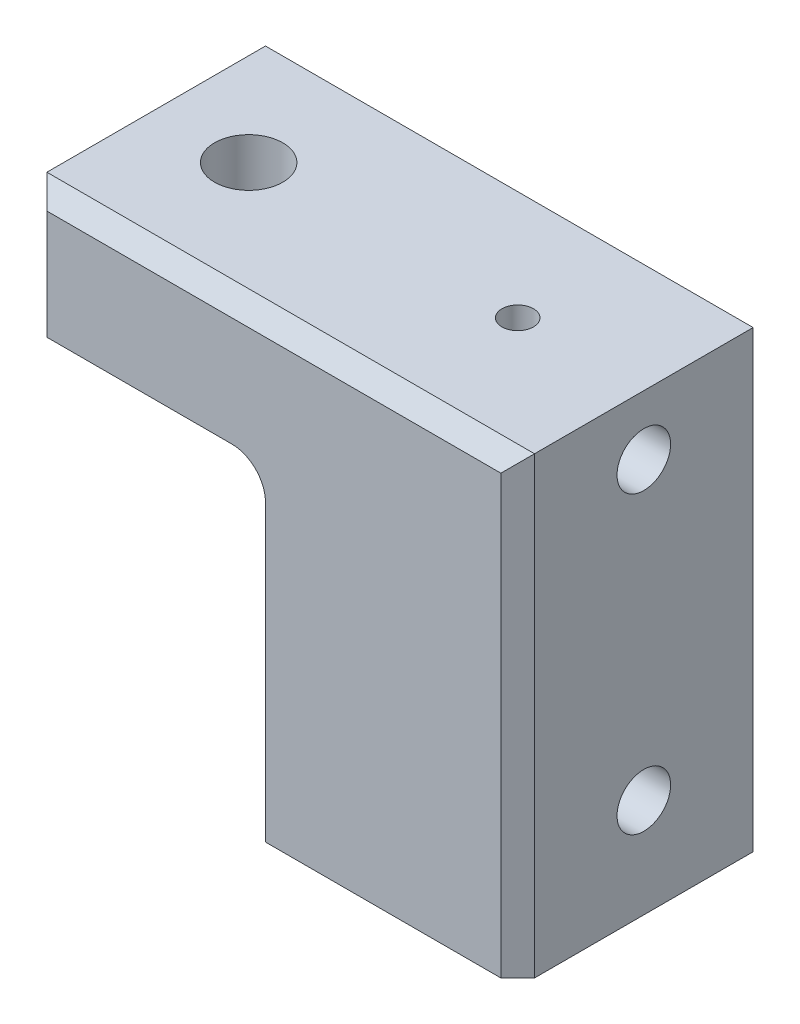
from build123d import *

# Parameters (mm, degrees)
EXTRUDE1_DEPTH                               = 38.1
F_3_8_CLEARANCE_HOLE1_D                      = 10.31748
TAPPED_HOLE_FOR_1_4_20_HELICOIL3_D           = 6.7564
TAPPED_HOLE_FOR_1_4_20_HELICOIL3_DEPTH       = 22.86
TAPPED_HOLE_FOR_1_4_20_HELICOIL3_CBORE_D     = 8.09498
TAPPED_HOLE_FOR_1_4_20_HELICOIL3_CBORE_DEPTH = 15.748
TAPPED_HOLE_FOR_1_4_20_HELICOIL3_TIP         = 2.029827343
TAPPED_HOLE_FOR_1_4_20_HELICOIL1_D           = 6.7564
TAPPED_HOLE_FOR_1_4_20_HELICOIL1_CBORE_D     = 8.09498
TAPPED_HOLE_FOR_1_4_20_HELICOIL1_CBORE_DEPTH = 15.748
FILLET1_R                                    = 5.08
F_3_16_0_1875_DIAMETER_HOLE1_REACH           = 70.58
F_3_16_0_1875_DIAMETER_HOLE1_BORE_R          = 2.38125
CHAMFER1_SIZE                                = 2.54


with BuildPart() as part:
    # Sketch1 → Extrude1 (new body)
    with BuildSketch(Plane.XY):
        Polygon((-73.66, 49.53), (-73.66, 68.58), (0, 68.58), (0, 0), (-38.1, 0), (-38.1, 49.53), align=None)
    extrude(amount=EXTRUDE1_DEPTH)

    # 3/8 Clearance Hole1 (through all)
    with Locations(Plane(origin=(-59.69, 68.58, 19.05), x_dir=(0, 0, 1), z_dir=(0, 1, 0))):
        with Locations((0, 0)):
            Hole(F_3_8_CLEARANCE_HOLE1_D / 2)

    # Tapped Hole for 1/4-20 Helicoil3
    with Locations(Plane(origin=(0, 59.563, 19.05), x_dir=(0, 0, 1), z_dir=(1, 0, 0))):
        with Locations((0, 0)):
            CounterBoreHole(TAPPED_HOLE_FOR_1_4_20_HELICOIL3_D / 2, TAPPED_HOLE_FOR_1_4_20_HELICOIL3_CBORE_D / 2, TAPPED_HOLE_FOR_1_4_20_HELICOIL3_CBORE_DEPTH, depth=TAPPED_HOLE_FOR_1_4_20_HELICOIL3_DEPTH)
            with Locations((0, 0, -(TAPPED_HOLE_FOR_1_4_20_HELICOIL3_DEPTH + TAPPED_HOLE_FOR_1_4_20_HELICOIL3_TIP / 2))):  # 118° drill point
                Cone(0, TAPPED_HOLE_FOR_1_4_20_HELICOIL3_D / 2, TAPPED_HOLE_FOR_1_4_20_HELICOIL3_TIP, mode=Mode.SUBTRACT)

    # Tapped Hole for 1/4-20 Helicoil1 (through all)
    with Locations(Plane(origin=(0, 14.986, 19.05), x_dir=(0, 0, 1), z_dir=(1, 0, 0))):
        with Locations((0, 0)):
            CounterBoreHole(TAPPED_HOLE_FOR_1_4_20_HELICOIL1_D / 2, TAPPED_HOLE_FOR_1_4_20_HELICOIL1_CBORE_D / 2, TAPPED_HOLE_FOR_1_4_20_HELICOIL1_CBORE_DEPTH)

    # Fillet1
    fillet1_edges = [part.edges().sort_by_distance(p)[0] for p in [
        (-38.1, 49.53, 19.05),
    ]]
    fillet(fillet1_edges, radius=FILLET1_R)

    # 3/16 (0.1875) Diameter Hole1 bore (on position points) → 3/16 (0.1875) Diameter Hole1 (cut, up to next)
    with BuildSketch(Plane(origin=(-19.05, 68.58, 19.05), x_dir=(0, 0, 1), z_dir=(0, 1, 0)), mode=Mode.PRIVATE) as f_3_16_0_1875_diameter_hole1_sk1:
        Circle(F_3_16_0_1875_DIAMETER_HOLE1_BORE_R)
    f_3_16_0_1875_diameter_hole1_tool1 = extrude(f_3_16_0_1875_diameter_hole1_sk1.sketch, amount=-F_3_16_0_1875_DIAMETER_HOLE1_REACH, mode=Mode.PRIVATE) & part.part
    add(f_3_16_0_1875_diameter_hole1_tool1.solids().sort_by_distance((-19.05, 68.58, 19.05))[0], mode=Mode.SUBTRACT)

    # Chamfer1
    chamfer1_edges = [part.edges().sort_by_distance(p)[0] for p in [
        (0, 34.29, 38.1),
        (-36.83, 68.58, 38.1),
        (-73.66, 59.055, 38.1),
        (-73.66, 59.055, 0),
        (-36.83, 68.58, 0),
        (0, 34.29, 0),
    ]]
    chamfer(chamfer1_edges, length=CHAMFER1_SIZE)


solid = part.part
